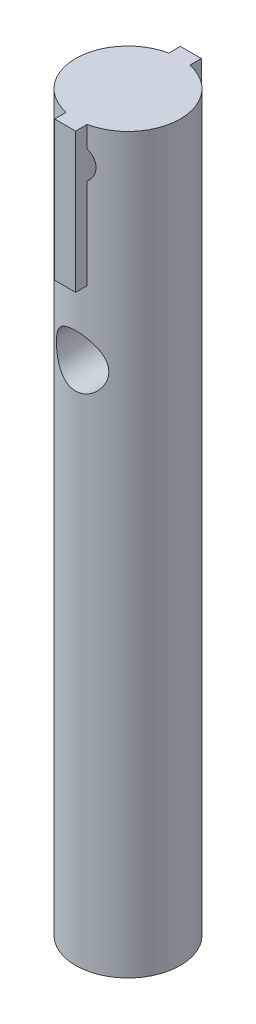
from build123d import *

# Parameters (mm, degrees)
SKETCH1_R               = 7.5
BOSS_EXTRUDE1_DEPTH     = 105
CUT_EXTRUDE1_DEPTH      = 106.534354596
CUT_EXTRUDE1_DEPTH_BACK = 106.534354596
CUT_EXTRUDE2_DEPTH      = 10
CUT_EXTRUDE2_DEPTH_BACK = 10
SKETCH3_R               = 2.5
SKETCH4_W               = 3
SKETCH4_H               = 18
BOSS_EXTRUDE2_DEPTH     = 20


with BuildPart() as part:
    # Sketch1 → Boss-Extrude1 (new body)
    with BuildSketch(Plane(origin=(0, 0, 0), x_dir=(1, 0, 0), z_dir=(0, 1, 0))):
        Circle(SKETCH1_R)
    extrude(amount=BOSS_EXTRUDE1_DEPTH)

    # Sketch2 → Cut-Extrude1 (cut, two sides: drawn at the far end of the back side and taken through both)
    with BuildSketch(Plane.XY.offset(-CUT_EXTRUDE1_DEPTH_BACK)):
        with BuildLine():
            ThreePointArc((0, 78.75), (-2.651650429, 72.348349571), (3.75, 75))
            ThreePointArc((3.75, 75), (2.651650429, 77.651650429), (0, 78.75))
        make_face()
    extrude(amount=CUT_EXTRUDE1_DEPTH + CUT_EXTRUDE1_DEPTH_BACK, mode=Mode.SUBTRACT)

    # Sketch3 → Cut-Extrude2 (cut, two sides: drawn at the far end of the back side and taken through both)
    with BuildSketch(Plane.XY.offset(-CUT_EXTRUDE2_DEPTH_BACK)):
        with Locations((0, 100)):
            Circle(SKETCH3_R)
    extrude(amount=CUT_EXTRUDE2_DEPTH + CUT_EXTRUDE2_DEPTH_BACK, mode=Mode.SUBTRACT)

    # Sketch4 → Boss-Extrude2 (add)
    with BuildSketch(Plane(origin=(0, 105, 0), x_dir=(1, 0, 0), z_dir=(0, 1, 0))):
        Rectangle(SKETCH4_W, SKETCH4_H)
    extrude(amount=-BOSS_EXTRUDE2_DEPTH)


solid = part.part
